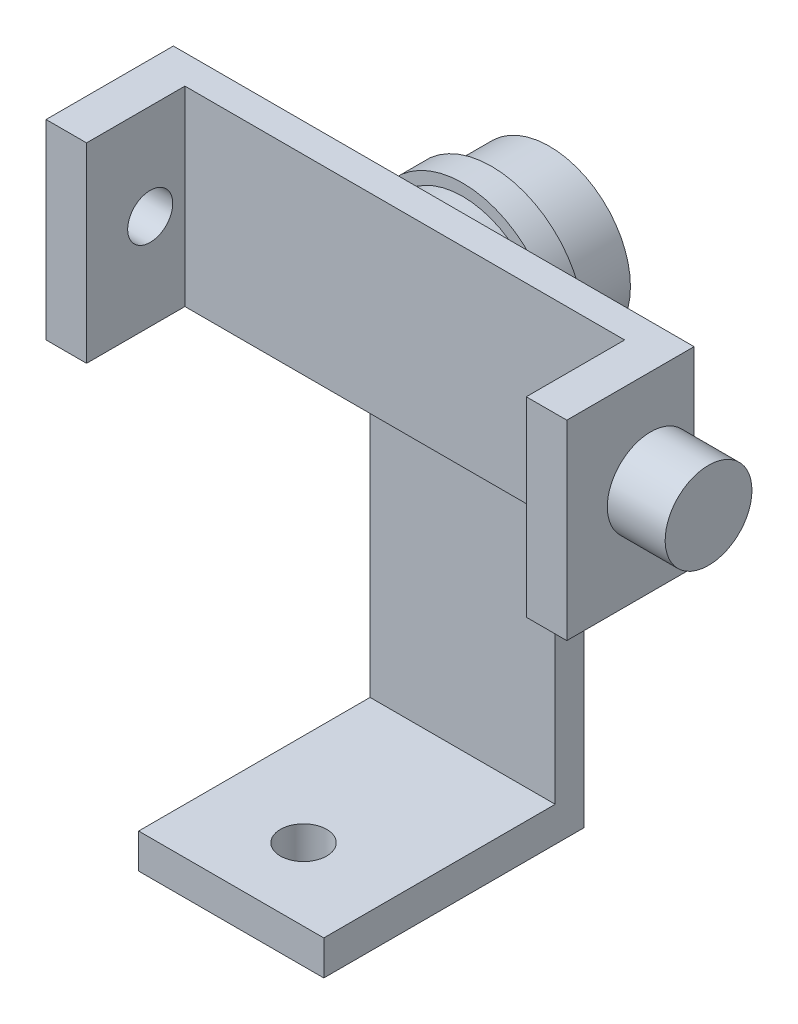
from build123d import *

# Parameters (mm, degrees)
SKETCH1_W                = 32
SKETCH1_H                = 45
SKETCH1_R                = 4
BOSS_EXTRUDE1_DEPTH      = 6
SKETCH2_W                = 32
SKETCH2_H                = 5
BOSS_EXTRUDE2_DEPTH      = 85
CUT_EXTRUDE1_DEPTH       = 85
BOSS_EXTRUDE4_DEPTH      = 5
BOSS_EXTRUDE4_DEPTH_BACK = 15
SKETCH5_W                = 90
SKETCH5_H                = 33
BOSS_EXTRUDE5_DEPTH      = 5
SKETCH6_W                = 7
SKETCH6_H                = 33
BOSS_EXTRUDE6_DEPTH      = 17
SKETCH7_R                = 7.5
BOSS_EXTRUDE7_DEPTH      = 10
SKETCH8_R                = 3.894699497
CUT_EXTRUDE2_DEPTH       = 10


with BuildPart() as part:
    # Sketch1 → Boss-Extrude1 (new body)
    with BuildSketch(Plane(origin=(0, 0, 0), x_dir=(1, 0, 0), z_dir=(0, 1, 0))):
        with Locations((0, 10)):
            Rectangle(SKETCH1_W, SKETCH1_H)
        Circle(SKETCH1_R, mode=Mode.SUBTRACT)
    extrude(amount=BOSS_EXTRUDE1_DEPTH)

    # Sketch2 → Boss-Extrude2 (add)
    with BuildSketch(Plane(origin=(0, 6, 0), x_dir=(1, 0, 0), z_dir=(0, 1, 0))):
        with Locations((0, 30)):
            Rectangle(SKETCH2_W, SKETCH2_H)
    extrude(amount=BOSS_EXTRUDE2_DEPTH)

    # Sketch3 → Cut-Extrude1 (cut)
    with BuildSketch(Plane.XY.offset(-27.5)):
        with BuildLine():
            Line((-16, 91), (-16, 75))
            ThreePointArc((-16, 75), (-11.313708499, 86.313708499), (0, 91))
            Line((0, 91), (-16, 91))
        make_face()
        with BuildLine():
            ThreePointArc((0, 91), (11.313708499, 86.313708499), (16, 75))
            Line((16, 75), (16, 91))
            Line((16, 91), (0, 91))
        make_face()
    extrude(amount=-CUT_EXTRUDE1_DEPTH, mode=Mode.SUBTRACT)

    # Sketch4 → Boss-Extrude4 (add, two sides)
    with BuildSketch(Plane.XY.offset(-27.5)) as boss_extrude4_sk:
        with BuildLine():
            ThreePointArc((14, 75), (0, 89), (-14, 75))
            Line((-14, 75), (14, 75))
        make_face()
        with BuildLine():
            Line((14, 75), (-14, 75))
            ThreePointArc((-14, 75), (0, 61), (14, 75))
        make_face()
    extrude(amount=BOSS_EXTRUDE4_DEPTH)
    extrude(boss_extrude4_sk.sketch, amount=-BOSS_EXTRUDE4_DEPTH_BACK)

    # Sketch5 → Boss-Extrude5 (add)
    with BuildSketch(Plane.XY.offset(-22.5)):
        with Locations((0, 75)):
            Rectangle(SKETCH5_W, SKETCH5_H)
    extrude(amount=BOSS_EXTRUDE5_DEPTH)

    # Sketch6 → Boss-Extrude6 (add)
    with BuildSketch(Plane.XY.offset(-17.5)):
        with Locations((-41.5, 75)):
            Rectangle(SKETCH6_W, SKETCH6_H)
        with Locations((41.5, 75)):
            Rectangle(SKETCH6_W, SKETCH6_H)
    extrude(amount=BOSS_EXTRUDE6_DEPTH)

    # Sketch7 → Boss-Extrude7 (add)
    with BuildSketch(Plane(origin=(45, 0, 0), x_dir=(0, 0, -1), z_dir=(1, 0, 0))):
        with Locations((15, 75)):
            Circle(SKETCH7_R)
    extrude(amount=BOSS_EXTRUDE7_DEPTH)

    # Sketch8 → Cut-Extrude2 (cut)
    with BuildSketch(Plane.ZY.offset(45)):
        with Locations((-11.5, 75)):
            Circle(SKETCH8_R)
    extrude(amount=-CUT_EXTRUDE2_DEPTH, mode=Mode.SUBTRACT)


solid = part.part
